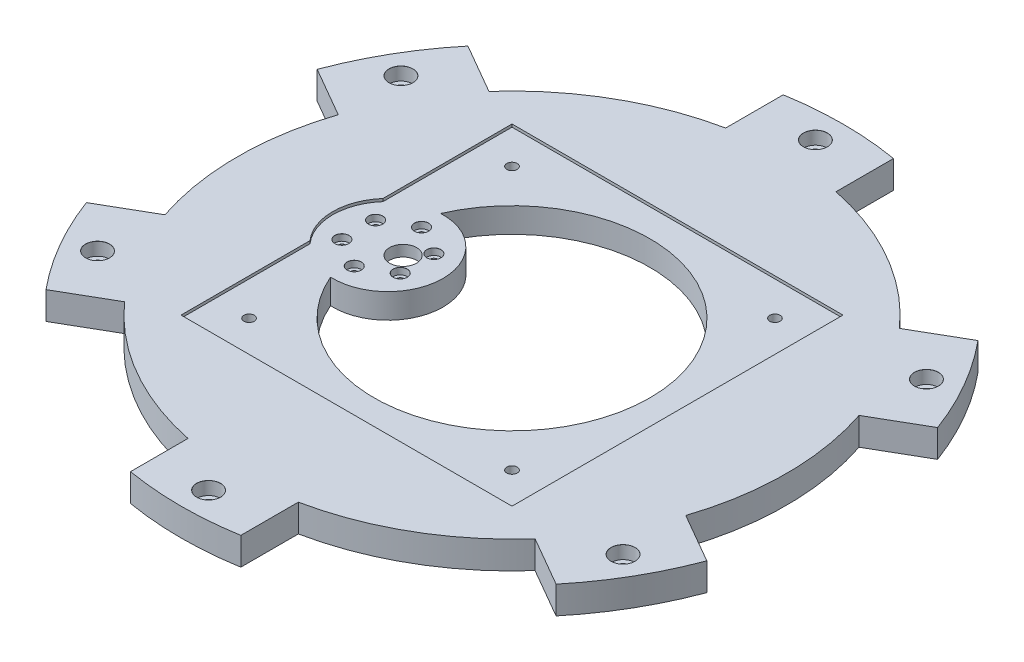
from build123d import *

# Parameters (mm, degrees)
BOSS_EXTRUDE1_DEPTH           = 12.7
SKETCH2_R                     = 63.5
CUT_EXTRUDE2_DEPTH            = 12.7
CUT_EXTRUDE3_DEPTH            = 1.27
SKETCH4_R                     = 2.4003
CUT_EXTRUDE4_DEPTH            = 2.27
CUT_EXTRUDE4_DEPTH_BACK       = 12.43
CBORE_FOR_M6_SHCS2_AT_2_COUNT = 2
CBORE_FOR_M6_SHCS2_AT_2_PITCH = 139.7
CBORE_FOR_M6_SHCS2_AT_3_COUNT = 2
CBORE_FOR_M6_SHCS2_AT_3_PITCH = 139.7
CBORE_FOR_M6_SHCS2_AT_4_COUNT = 2
CBORE_FOR_M6_SHCS2_AT_4_PITCH = 139.7
CBORE_FOR_M6_SHCS2_AT_5_COUNT = 2
CBORE_FOR_M6_SHCS2_AT_5_PITCH = 139.7
CBORE_FOR_M6_SHCS2_AT_6_COUNT = 2
CBORE_FOR_M6_SHCS2_AT_6_PITCH = 139.7
CBORE_FOR_M6_SHCS2_AT_7_COUNT = 2
CBORE_FOR_M6_SHCS2_AT_7_PITCH = 139.7
SKETCH7_R                     = 25.4
BOSS_EXTRUDE2_DEPTH           = 11.43
SKETCH8_R                     = 18.542
CUT_EXTRUDE5_DEPTH            = 6.35
CBORE_FOR_M3_SHCS1_AT_2_COUNT = 2
CBORE_FOR_M3_SHCS1_AT_2_PITCH = 15.499969
CBORE_FOR_M3_SHCS1_AT_3_COUNT = 2
CBORE_FOR_M3_SHCS1_AT_3_PITCH = 26.846733824
CBORE_FOR_M3_SHCS1_AT_4_COUNT = 2
CBORE_FOR_M3_SHCS1_AT_4_PITCH = 30.999938
CBORE_FOR_M3_SHCS1_AT_5_COUNT = 2
CBORE_FOR_M3_SHCS1_AT_5_PITCH = 26.846733824
CBORE_FOR_M3_SHCS1_AT_6_COUNT = 2
CBORE_FOR_M3_SHCS1_AT_6_PITCH = 15.499969
SKETCH11_R                    = 6.223
CUT_EXTRUDE6_DEPTH            = 11.43


with BuildPart() as part:
    # Sketch1 → Boss-Extrude1 (new body)
    with BuildSketch(Plane(origin=(0, 0, 0), x_dir=(1, 0, 0), z_dir=(0, 1, 0))):
        with BuildLine():
            Line((-25.4, 123.785916909), (-25.4, 150.268426491))
            ThreePointArc((-25.4, 150.268426491), (0, 152.4), (25.4, 150.268426491))
            Line((25.4, 150.268426491), (25.4, 123.785916909))
            ThreePointArc((25.4, 123.785916909), (63.1825, 109.435300149), (94.501748674, 83.890003711))
            Line((94.501748674, 83.890003711), (117.436274728, 97.131258501))
            ThreePointArc((117.436274728, 97.131258501), (131.982271537, 76.2), (142.836274728, 53.137167989))
            Line((142.836274728, 53.137167989), (119.901748674, 39.895913198))
            ThreePointArc((119.901748674, 39.895913198), (126.365, 0), (119.901748674, -39.895913198))
            Line((119.901748674, -39.895913198), (142.836274728, -53.137167989))
            ThreePointArc((142.836274728, -53.137167989), (131.982271537, -76.2), (117.436274728, -97.131258501))
            Line((117.436274728, -97.131258501), (94.501748674, -83.890003711))
            ThreePointArc((94.501748674, -83.890003711), (63.1825, -109.435300149), (25.4, -123.785916909))
            Line((25.4, -123.785916909), (25.4, -150.268426491))
            ThreePointArc((25.4, -150.268426491), (0, -152.4), (-25.4, -150.268426491))
            Line((-25.4, -150.268426491), (-25.4, -123.785916909))
            ThreePointArc((-25.4, -123.785916909), (-63.1825, -109.435300149), (-94.501748674, -83.890003711))
            Line((-94.501748674, -83.890003711), (-117.436274728, -97.131258501))
            ThreePointArc((-117.436274728, -97.131258501), (-131.982271537, -76.2), (-142.836274728, -53.137167989))
            Line((-142.836274728, -53.137167989), (-119.901748674, -39.895913198))
            ThreePointArc((-119.901748674, -39.895913198), (-126.365, 0), (-119.901748674, 39.895913198))
            Line((-119.901748674, 39.895913198), (-142.836274728, 53.137167989))
            ThreePointArc((-142.836274728, 53.137167989), (-131.982271537, 76.2), (-117.436274728, 97.131258501))
            Line((-117.436274728, 97.131258501), (-94.501748674, 83.890003711))
            ThreePointArc((-94.501748674, 83.890003711), (-63.1825, 109.435300149), (-25.4, 123.785916909))
        make_face()
    extrude(amount=BOSS_EXTRUDE1_DEPTH)

    # Sketch2 → Cut-Extrude2 (cut)
    with BuildSketch(Plane(origin=(0, 0, 0), x_dir=(1, 0, 0), z_dir=(0, 1, 0))):
        Circle(SKETCH2_R)
    extrude(amount=CUT_EXTRUDE2_DEPTH, mode=Mode.SUBTRACT)

    # Sketch3 → Cut-Extrude3 (cut)
    with BuildSketch(Plane(origin=(0, 12.7, 0), x_dir=(1, 0, 0), z_dir=(0, 1, 0))):
        with BuildLine():
            Line((-76.2, 16.800520825), (-76.2, 76.2))
            Line((-76.2, 76.2), (76.2, 76.2))
            Line((76.2, 76.2), (76.2, -76.2))
            Line((76.2, -76.2), (-76.2, -76.2))
            Line((-76.2, -76.2), (-76.2, -16.800520825))
            ThreePointArc((-76.2, -16.800520825), (-82.55, 0), (-76.2, 16.800520825))
        make_face()
    extrude(amount=-CUT_EXTRUDE3_DEPTH, mode=Mode.SUBTRACT)

    # Sketch4 → Cut-Extrude4 (cut, two sides)
    with BuildSketch(Plane(origin=(0, 11.43, 0), x_dir=(1, 0, 0), z_dir=(0, 1, 0))) as cut_extrude4_sk:
        with Locations((-60.5282, 60.5282)):
            Circle(SKETCH4_R)
        with Locations((-60.5282, -60.5282)):
            Circle(SKETCH4_R)
        with Locations((60.5282, -60.5282)):
            Circle(SKETCH4_R)
        with Locations((60.5282, 60.5282)):
            Circle(SKETCH4_R)
    extrude(amount=CUT_EXTRUDE4_DEPTH, mode=Mode.SUBTRACT)
    extrude(cut_extrude4_sk.sketch, amount=-CUT_EXTRUDE4_DEPTH_BACK, mode=Mode.SUBTRACT)

    # Sketch6 → CBORE for M6 SHCS2 (revolve, cut)
    with BuildSketch(Plane(origin=(0, 12.7, 0), x_dir=(0, 0, 1), z_dir=(1, 0, 0))):
        Polygon((0, 0), (0, 12.7), (3.3, 12.7), (3.3, 6), (5.5, 6), (5.5, 0.025), (5.525, 0), align=None)
    cbore_for_m6_shcs2 = revolve(axis=Axis((0, 19.05, 0), (0, -1, 0)), mode=Mode.SUBTRACT)

    # CBORE for M6 SHCS2 at 2: CBORE for M6 SHCS2 ×2
    with Locations(*[(0, 0, -i * CBORE_FOR_M6_SHCS2_AT_2_PITCH) for i in range(1, CBORE_FOR_M6_SHCS2_AT_2_COUNT)]):
        add(cbore_for_m6_shcs2, mode=Mode.SUBTRACT)

    # CBORE for M6 SHCS2 at 3: CBORE for M6 SHCS2 ×2
    with Locations(*[Vector(0.866025404, 0, -0.5) * (i * CBORE_FOR_M6_SHCS2_AT_3_PITCH) for i in range(1, CBORE_FOR_M6_SHCS2_AT_3_COUNT)]):
        add(cbore_for_m6_shcs2, mode=Mode.SUBTRACT)

    # CBORE for M6 SHCS2 at 4: CBORE for M6 SHCS2 ×2
    with Locations(*[Vector(0.866025404, 0, 0.5) * (i * CBORE_FOR_M6_SHCS2_AT_4_PITCH) for i in range(1, CBORE_FOR_M6_SHCS2_AT_4_COUNT)]):
        add(cbore_for_m6_shcs2, mode=Mode.SUBTRACT)

    # CBORE for M6 SHCS2 at 5: CBORE for M6 SHCS2 ×2
    with Locations(*[(0, 0, i * CBORE_FOR_M6_SHCS2_AT_5_PITCH) for i in range(1, CBORE_FOR_M6_SHCS2_AT_5_COUNT)]):
        add(cbore_for_m6_shcs2, mode=Mode.SUBTRACT)

    # CBORE for M6 SHCS2 at 6: CBORE for M6 SHCS2 ×2
    with Locations(*[Vector(-0.866025404, 0, 0.5) * (i * CBORE_FOR_M6_SHCS2_AT_6_PITCH) for i in range(1, CBORE_FOR_M6_SHCS2_AT_6_COUNT)]):
        add(cbore_for_m6_shcs2, mode=Mode.SUBTRACT)

    # CBORE for M6 SHCS2 at 7: CBORE for M6 SHCS2 ×2
    with Locations(*[Vector(-0.866025404, 0, -0.5) * (i * CBORE_FOR_M6_SHCS2_AT_7_PITCH) for i in range(1, CBORE_FOR_M6_SHCS2_AT_7_COUNT)]):
        add(cbore_for_m6_shcs2, mode=Mode.SUBTRACT)

    # Sketch7 → Boss-Extrude2 (add)
    with BuildSketch(Plane.XZ):
        with Locations((-57.15, 0)):
            Circle(SKETCH7_R)
    extrude(amount=-BOSS_EXTRUDE2_DEPTH)

    # Sketch8 → Cut-Extrude5 (cut)
    with BuildSketch(Plane(origin=(0, 0, 0), x_dir=(-1, 0, 0), z_dir=(0, -1, 0))):
        with Locations((57.15, 0)):
            Circle(SKETCH8_R)
    extrude(amount=-CUT_EXTRUDE5_DEPTH, mode=Mode.SUBTRACT)

    # Sketch10 → CBORE for M3 SHCS1 (revolve, cut)
    with BuildSketch(Plane(origin=(-70.573366912, 11.43, 7.7499845), x_dir=(0, 0, 1), z_dir=(1, 0, 0))):
        Polygon((0, 0), (0, 6.101463052), (1.7, 5.08), (1.7, 3), (3.25, 3), (3.25, 0.025), (3.275, 0), align=None)
    cbore_for_m3_shcs1 = revolve(axis=Axis((-70.573366912, 17.78, 7.7499845), (0, -1, 0)), mode=Mode.SUBTRACT)

    # CBORE for M3 SHCS1 at 2: CBORE for M3 SHCS1 ×2
    with Locations(*[Vector(0.866025404, 0, 0.5) * (i * CBORE_FOR_M3_SHCS1_AT_2_PITCH) for i in range(1, CBORE_FOR_M3_SHCS1_AT_2_COUNT)]):
        add(cbore_for_m3_shcs1, mode=Mode.SUBTRACT)

    # CBORE for M3 SHCS1 at 3: CBORE for M3 SHCS1 ×2
    with Locations(*[(i * CBORE_FOR_M3_SHCS1_AT_3_PITCH, 0, 0) for i in range(1, CBORE_FOR_M3_SHCS1_AT_3_COUNT)]):
        add(cbore_for_m3_shcs1, mode=Mode.SUBTRACT)

    # CBORE for M3 SHCS1 at 4: CBORE for M3 SHCS1 ×2
    with Locations(*[Vector(0.866025404, 0, -0.5) * (i * CBORE_FOR_M3_SHCS1_AT_4_PITCH) for i in range(1, CBORE_FOR_M3_SHCS1_AT_4_COUNT)]):
        add(cbore_for_m3_shcs1, mode=Mode.SUBTRACT)

    # CBORE for M3 SHCS1 at 5: CBORE for M3 SHCS1 ×2
    with Locations(*[Vector(0.5, 0, -0.866025404) * (i * CBORE_FOR_M3_SHCS1_AT_5_PITCH) for i in range(1, CBORE_FOR_M3_SHCS1_AT_5_COUNT)]):
        add(cbore_for_m3_shcs1, mode=Mode.SUBTRACT)

    # CBORE for M3 SHCS1 at 6: CBORE for M3 SHCS1 ×2
    with Locations(*[(0, 0, -i * CBORE_FOR_M3_SHCS1_AT_6_PITCH) for i in range(1, CBORE_FOR_M3_SHCS1_AT_6_COUNT)]):
        add(cbore_for_m3_shcs1, mode=Mode.SUBTRACT)

    # Sketch11 → Cut-Extrude6 (cut)
    with BuildSketch(Plane.XZ):
        with Locations((-50.1500013, 0)):
            Circle(SKETCH11_R)
    extrude(amount=-CUT_EXTRUDE6_DEPTH, mode=Mode.SUBTRACT)


solid = part.part
